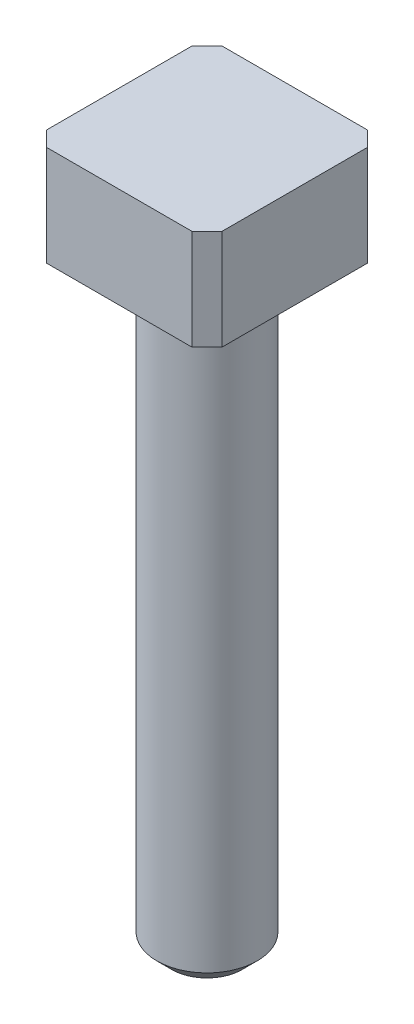
from build123d import *

# Parameters (mm, degrees)
SKETCH1_W           = 3.5
SKETCH1_H           = 3.5
BOSS_EXTRUDE1_DEPTH = 2
SKETCH2_R           = 1
BOSS_EXTRUDE2_DEPTH = 12
CHAMFER1_SIZE       = 0.3


with BuildPart() as part:
    # Sketch1 → Boss-Extrude1 (new body)
    with BuildSketch(Plane(origin=(0, 0, 0), x_dir=(1, 0, 0), z_dir=(0, 1, 0))):
        Rectangle(SKETCH1_W, SKETCH1_H)
    extrude(amount=BOSS_EXTRUDE1_DEPTH)

    # Sketch2 → Boss-Extrude2 (add)
    with BuildSketch(Plane(origin=(0, 0, 0), x_dir=(1, 0, 0), z_dir=(0, 1, 0))):
        Circle(SKETCH2_R)
    extrude(amount=-BOSS_EXTRUDE2_DEPTH)

    # Chamfer1
    chamfer1_edges = [part.edges().sort_by_distance(p)[0] for p in [
        (-1, -12, 0),
        (-1.75, 1, -1.75),
        (1.75, 1, -1.75),
        (1.75, 1, 1.75),
        (-1.75, 1, 1.75),
    ]]
    chamfer(chamfer1_edges, length=CHAMFER1_SIZE)


solid = part.part
